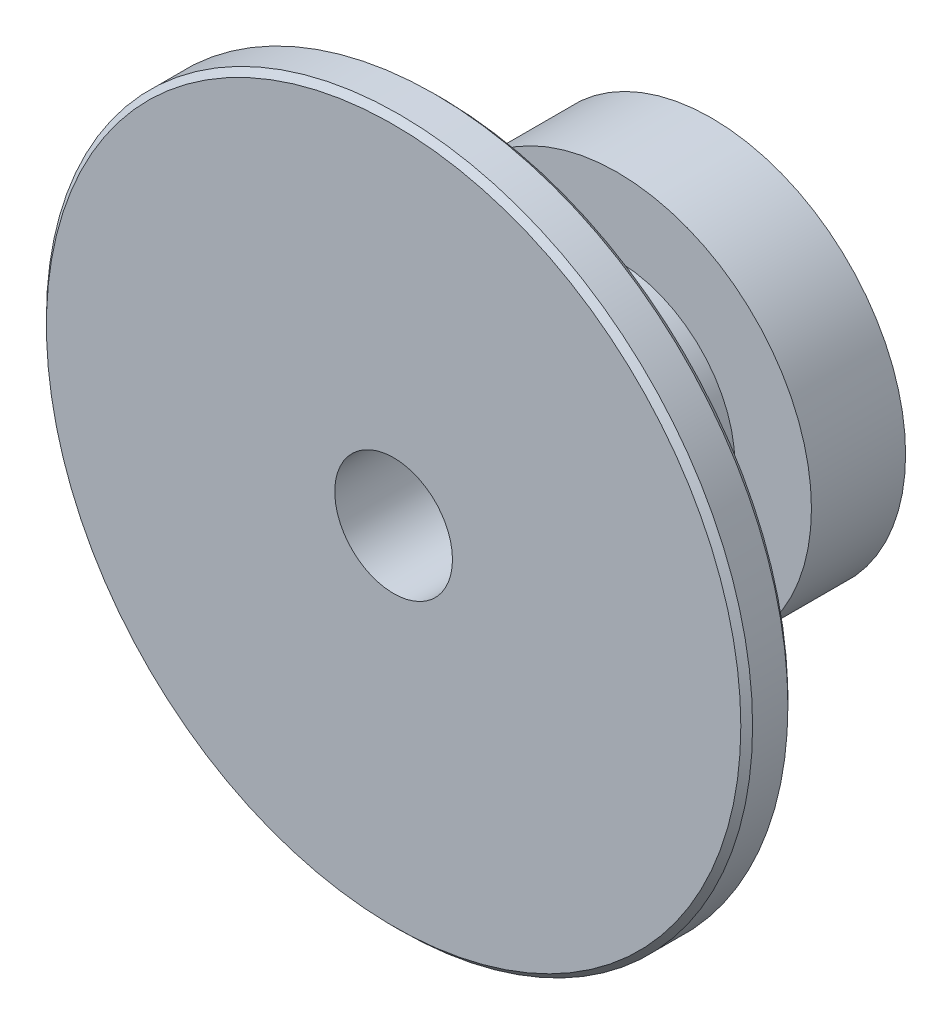
from build123d import *

# Parameters (mm, degrees)
CHAMFER1_SIZE      = 0.25
SKETCH2_R          = 2.5
CUT_EXTRUDE1_DEPTH = 10


with BuildPart() as part:
    # Sketch1 → Revolve1 (revolve)
    with BuildSketch(Plane(origin=(0, 0, 0), x_dir=(1, 0, 0), z_dir=(0, 1, 0))):
        Polygon((6, 0), (0, 0), (0, 6.5), (8.25, 6.5), (8.25, 2), (15, 2), (15, 0), align=None)
    revolve(axis=Axis((0, 0, 17.872516556), (0, 0, -1)))

    # Chamfer1
    chamfer1_edges = [part.edges().sort_by_distance(p)[0] for p in [
        (-15, 0, -2),
        (-15, 0, 0),
    ]]
    chamfer(chamfer1_edges, length=CHAMFER1_SIZE)

    # Sketch2 → Cut-Extrude1 (cut)
    with BuildSketch(Plane(origin=(0, 0, -6.5), x_dir=(-1, 0, 0), z_dir=(0, 0, -1))):
        Circle(SKETCH2_R)
    extrude(amount=-CUT_EXTRUDE1_DEPTH, mode=Mode.SUBTRACT)

    # Sketch5 → Revolve2 (revolve)
    with BuildSketch(Plane(origin=(0, 0, 0), x_dir=(1, 0, 0), z_dir=(0, 1, 0))):
        Polygon((2.5, 3.237551437), (2.5, 13.5), (8.25, 13.5), (8.25, 9.5), (5, 9.5), (5, 3.237551437), align=None)
    revolve(axis=Axis((0, 0, 0), (0, 0, -1)))


solid = part.part
